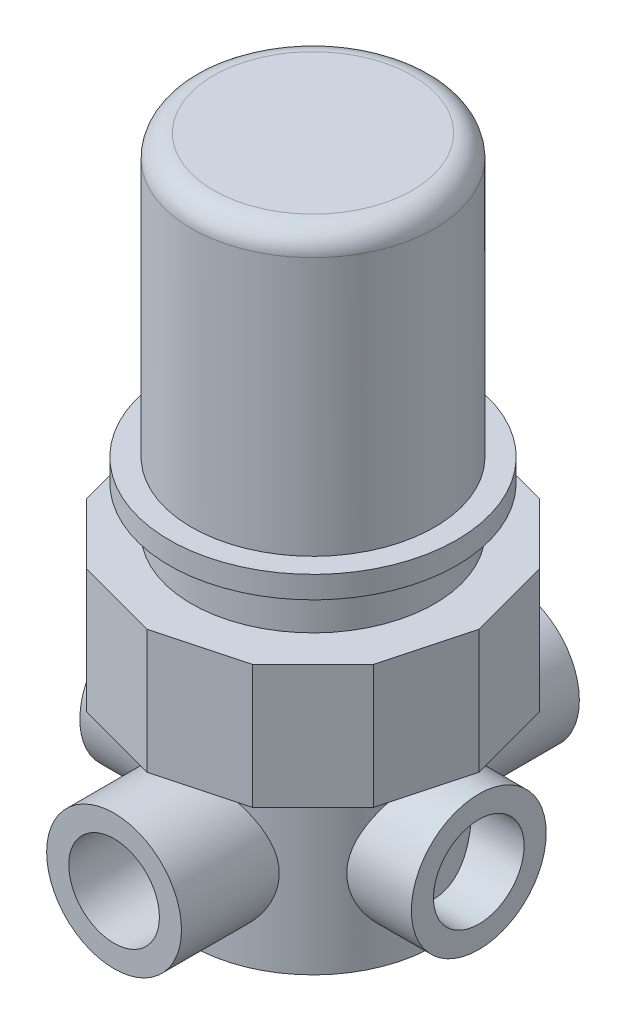
from build123d import *

# Parameters (mm, degrees)
CUT_EXTRUDE1_START  = -14.224
CUT_EXTRUDE1_DEPTH  = 14.224
BOSS_EXTRUDE1_START = -2.344817
SKETCH3_R           = 7.747
SKETCH3_R_2         = 5.207
BOSS_EXTRUDE1_DEPTH = 11.234817
CIRPATTERN1_COUNT   = 4
SKETCH4_R           = 7.747
CUT_EXTRUDE2_DEPTH  = 3.81
FILLET1_R           = 2.54


with BuildPart() as part:
    # Sketch1 → Revolve1 (revolve)
    with BuildSketch(Plane.XY):
        Polygon((0, 73.914), (13.97, 73.914), (13.97, 41.656), (16.51, 41.656), (16.51, 39.116), (13.97, 39.116), (13.97, 34.036), (19.05, 34.036), (19.05, 19.812), (13.97, 19.812), (13.97, 0), (0, 0), align=None)
    revolve(axis=Axis((0, 73.914, 0), (0, -1, 0)))

    # Sketch2 → Cut-Extrude1 (cut)
    with BuildSketch(Plane(origin=(0, 34.036, 0), x_dir=(1, 0, 0), z_dir=(0, 1, 0)).offset(CUT_EXTRUDE1_START)):
        with BuildLine():
            ThreePointArc((9.525, 16.497783942), (4.930502809, 18.400886991), (0, 19.05))
            Line((0, 19.05), (9.525, 16.497783942))
        make_face()
        with BuildLine():
            Line((-9.525, 16.497783942), (0, 19.05))
            ThreePointArc((0, 19.05), (-4.930502809, 18.400886991), (-9.525, 16.497783942))
        make_face()
        with BuildLine():
            Line((-16.497783942, 9.525), (-9.525, 16.497783942))
            ThreePointArc((-9.525, 16.497783942), (-13.470384182, 13.470384182), (-16.497783942, 9.525))
        make_face()
        with BuildLine():
            ThreePointArc((16.497783942, 9.525), (13.470384182, 13.470384182), (9.525, 16.497783942))
            Line((9.525, 16.497783942), (16.497783942, 9.525))
        make_face()
        with BuildLine():
            Line((-19.05, 0), (-16.497783942, 9.525))
            ThreePointArc((-16.497783942, 9.525), (-18.400886991, 4.930502809), (-19.05, 0))
        make_face()
        with BuildLine():
            ThreePointArc((19.05, 0), (18.400886991, 4.930502809), (16.497783942, 9.525))
            Line((16.497783942, 9.525), (19.05, 0))
        make_face()
        with BuildLine():
            Line((-16.497783942, -9.525), (-19.05, 0))
            ThreePointArc((-19.05, 0), (-18.400886991, -4.930502809), (-16.497783942, -9.525))
        make_face()
        with BuildLine():
            ThreePointArc((16.497783942, -9.525), (18.400886991, -4.930502809), (19.05, 0))
            Line((19.05, 0), (16.497783942, -9.525))
        make_face()
        with BuildLine():
            Line((-9.525, -16.497783942), (-16.497783942, -9.525))
            ThreePointArc((-16.497783942, -9.525), (-13.470384182, -13.470384182), (-9.525, -16.497783942))
        make_face()
        with BuildLine():
            ThreePointArc((9.525, -16.497783942), (13.470384182, -13.470384182), (16.497783942, -9.525))
            Line((16.497783942, -9.525), (9.525, -16.497783942))
        make_face()
        with BuildLine():
            Line((0, -19.05), (-9.525, -16.497783942))
            ThreePointArc((-9.525, -16.497783942), (-4.930502809, -18.400886991), (0, -19.05))
        make_face()
        with BuildLine():
            ThreePointArc((0, -19.05), (4.930502809, -18.400886991), (9.525, -16.497783942))
            Line((9.525, -16.497783942), (0, -19.05))
        make_face()
    extrude(amount=CUT_EXTRUDE1_DEPTH, mode=Mode.SUBTRACT)

    # Sketch3 → Boss-Extrude1 (add)
    with BuildSketch(Plane.XY.offset(13.97).offset(BOSS_EXTRUDE1_START)):
        with Locations((0, 9.906)):
            Circle(SKETCH3_R)
        with Locations((0, 9.906)):
            Circle(SKETCH3_R_2, mode=Mode.SUBTRACT)
    boss_extrude1 = extrude(amount=BOSS_EXTRUDE1_DEPTH)

    # CirPattern1: Boss-Extrude1 ×4 about axis
    cirpattern1_axis = Axis((0, 0, 0), (0, 1, 0))
    for i in range(1, CIRPATTERN1_COUNT):
        add(boss_extrude1.rotate(cirpattern1_axis, i * 360 / CIRPATTERN1_COUNT))

    # Sketch4 → Cut-Extrude2 (cut)
    with BuildSketch(Plane(origin=(22.86, 0, 0), x_dir=(0, 0, -1), z_dir=(1, 0, 0))):
        with Locations((0, 9.906)):
            Circle(SKETCH4_R)
    cut_extrude2 = extrude(amount=-CUT_EXTRUDE2_DEPTH, mode=Mode.SUBTRACT)

    # Mirror2: Cut-Extrude2 across plane
    add(cut_extrude2.mirror(Plane(origin=(0, 0, 0), x_dir=(0, 0, 1), z_dir=(1, 0, 0))), mode=Mode.SUBTRACT)

    # Fillet1
    fillet1_edges = [part.edges().sort_by_distance(p)[0] for p in [
        (-13.97, 73.914, 0),
    ]]
    fillet(fillet1_edges, radius=FILLET1_R)


solid = part.part
